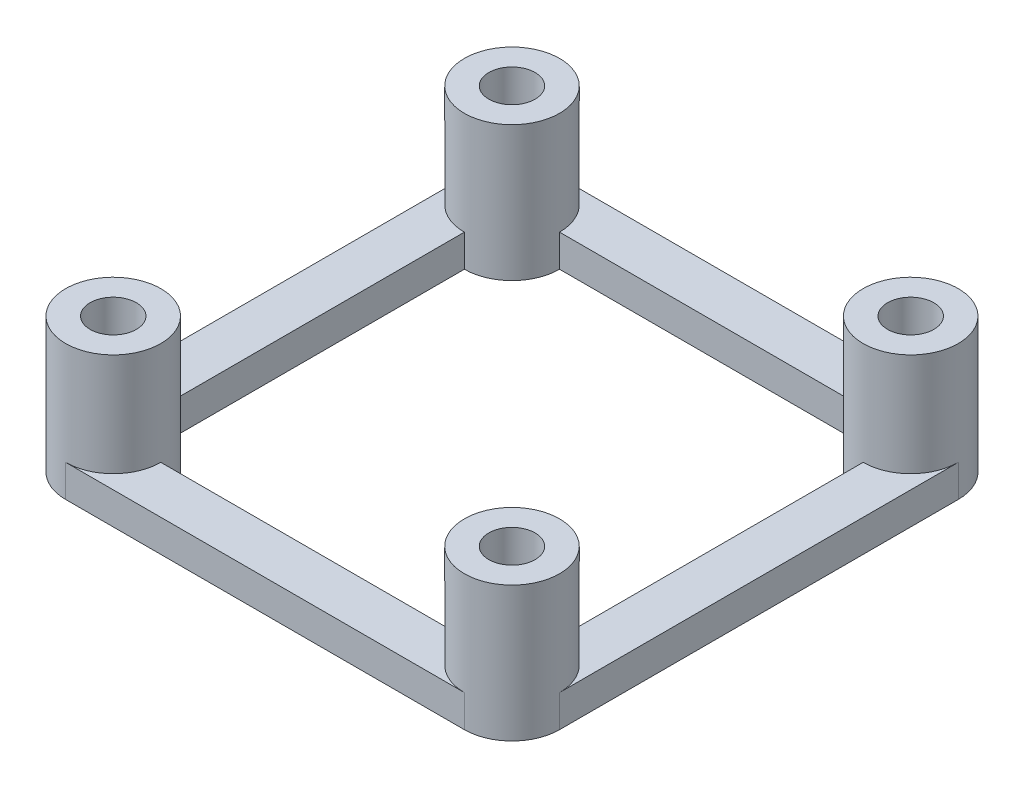
from build123d import *

# Parameters (mm, degrees)
SKETCH_1_R      = 1.8
EXTRUDE_1_DEPTH = 2.5
SKETCH_2_R      = 3.7
SKETCH_2_R_2    = 1.8
EXTRUDE_2_DEPTH = 8


with BuildPart() as part:
    # 草图1 → 凸台-拉伸1 (new body)
    with BuildSketch(Plane(origin=(0, 0, 0), x_dir=(1, 0, 0), z_dir=(0, 1, 0))):
        with BuildLine():
            Line((-19.2, 15.5), (-19.2, -15.5))
            ThreePointArc((-19.2, -15.5), (-18.11629509, -18.11629509), (-15.5, -19.2))
            Line((-15.5, -19.2), (15.5, -19.2))
            ThreePointArc((15.5, -19.2), (18.11629509, -18.11629509), (19.2, -15.5))
            Line((19.2, -15.5), (19.2, 15.5))
            ThreePointArc((19.2, 15.5), (18.11629509, 18.11629509), (15.5, 19.2))
            Line((15.5, 19.2), (-15.5, 19.2))
            ThreePointArc((-15.5, 19.2), (-18.11629509, 18.11629509), (-19.2, 15.5))
        make_face()
        with Locations((-15.5, 15.5)):
            Circle(SKETCH_1_R, mode=Mode.SUBTRACT)
        with Locations((15.5, 15.5)):
            Circle(SKETCH_1_R, mode=Mode.SUBTRACT)
        with Locations((-15.5, -15.5)):
            Circle(SKETCH_1_R, mode=Mode.SUBTRACT)
        with Locations((15.5, -15.5)):
            Circle(SKETCH_1_R, mode=Mode.SUBTRACT)
        with BuildLine():
            Line((-11.8, 15.5), (11.8, 15.5))
            ThreePointArc((11.8, 15.5), (12.88370491, 12.88370491), (15.5, 11.8))
            Line((15.5, 11.8), (15.5, -11.8))
            ThreePointArc((15.5, -11.8), (12.88370491, -12.88370491), (11.8, -15.5))
            Line((11.8, -15.5), (-11.8, -15.5))
            ThreePointArc((-11.8, -15.5), (-12.88370491, -12.88370491), (-15.5, -11.8))
            Line((-15.5, -11.8), (-15.5, 11.8))
            ThreePointArc((-15.5, 11.8), (-12.88370491, 12.88370491), (-11.8, 15.5))
        make_face(mode=Mode.SUBTRACT)
    extrude(amount=EXTRUDE_1_DEPTH)

    # 草图2 → 凸台-拉伸2 (add)
    with BuildSketch(Plane(origin=(0, 2.5, 0), x_dir=(1, 0, 0), z_dir=(0, 1, 0))):
        with Locations((-15.5, 15.5)):
            Circle(SKETCH_2_R)
        with Locations((-15.5, 15.5)):
            Circle(SKETCH_2_R_2, mode=Mode.SUBTRACT)
        with Locations((15.5, 15.5)):
            Circle(SKETCH_2_R)
        with Locations((15.5, 15.5)):
            Circle(SKETCH_2_R_2, mode=Mode.SUBTRACT)
        with Locations((15.5, -15.5)):
            Circle(SKETCH_2_R)
        with Locations((15.5, -15.5)):
            Circle(SKETCH_2_R_2, mode=Mode.SUBTRACT)
        with Locations((-15.5, -15.5)):
            Circle(SKETCH_2_R)
        with Locations((-15.5, -15.5)):
            Circle(SKETCH_2_R_2, mode=Mode.SUBTRACT)
    extrude(amount=EXTRUDE_2_DEPTH)


solid = part.part
